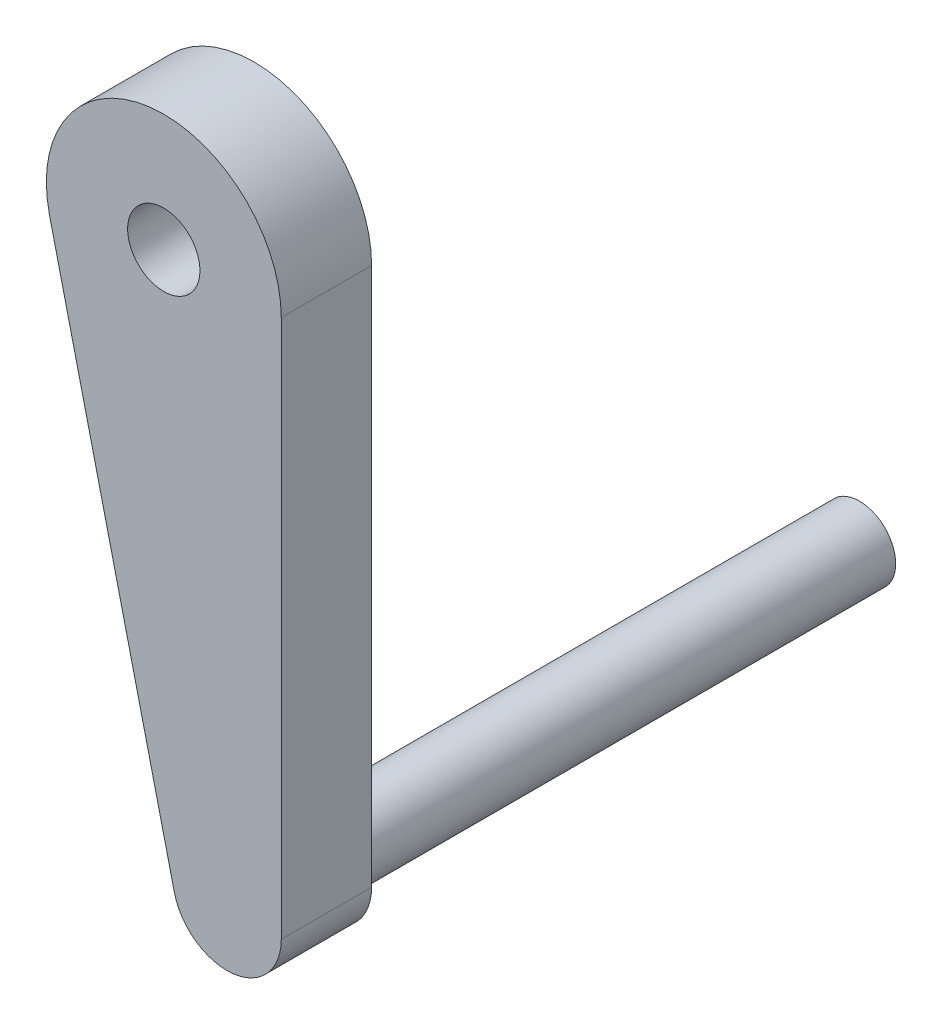
from build123d import *

# Parameters (mm, degrees)
BOSS_EXTRUDE1_DEPTH = 6.35
SKETCH2_R           = 2.54
BOSS_EXTRUDE2_DEPTH = 38.1
SKETCH3_R           = 2.54
CUT_EXTRUDE1_DEPTH  = 38.1


with BuildPart() as part:
    # Sketch1 → Boss-Extrude1 (new body)
    with BuildSketch(Plane.XY):
        with BuildLine():
            Line((8.255, 0), (8.255, -37.839819965))
            ThreePointArc((8.255, -37.839819965), (4.8895, -41.623801962), (0.738716667, -38.722749098))
            Line((0.738716667, -38.722749098), (-8.030280556, -1.91301312))
            ThreePointArc((-8.030280556, -1.91301312), (-0.963083333, 8.198627659), (8.255, 0))
        make_face()
    extrude(amount=BOSS_EXTRUDE1_DEPTH)

    # Sketch2 → Boss-Extrude2 (add)
    with BuildSketch(Plane(origin=(0, 0, 0), x_dir=(-1, 0, 0), z_dir=(0, 0, -1))):
        with Locations((-4.445, -37.839819965)):
            Circle(SKETCH2_R)
    extrude(amount=BOSS_EXTRUDE2_DEPTH)

    # Sketch3 → Cut-Extrude1 (cut)
    with BuildSketch(Plane.XY.offset(6.35)):
        Circle(SKETCH3_R)
    extrude(amount=-CUT_EXTRUDE1_DEPTH, mode=Mode.SUBTRACT)


solid = part.part
